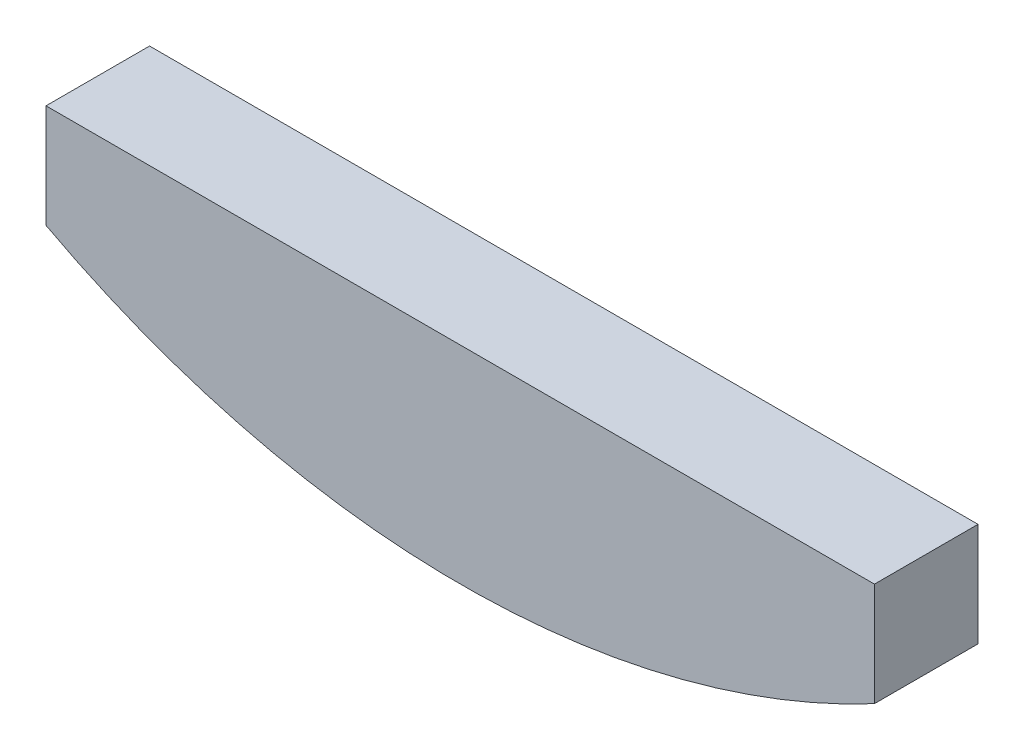
from build123d import *

# Parameters (mm, degrees)
BOSS_EXTRUDE1_DEPTH = 6.35


with BuildPart() as part:
    # Sketch1 → Boss-Extrude1 (new body)
    with BuildSketch(Plane.XY):
        with BuildLine():
            Line((0, 0), (0, 6.35))
            Line((0, 6.35), (50.8, 6.35))
            Line((50.8, 6.35), (50.8, 0))
            ThreePointArc((50.8, 0), (25.4, -6.35), (0, 0))
        make_face()
    extrude(amount=BOSS_EXTRUDE1_DEPTH)


solid = part.part
